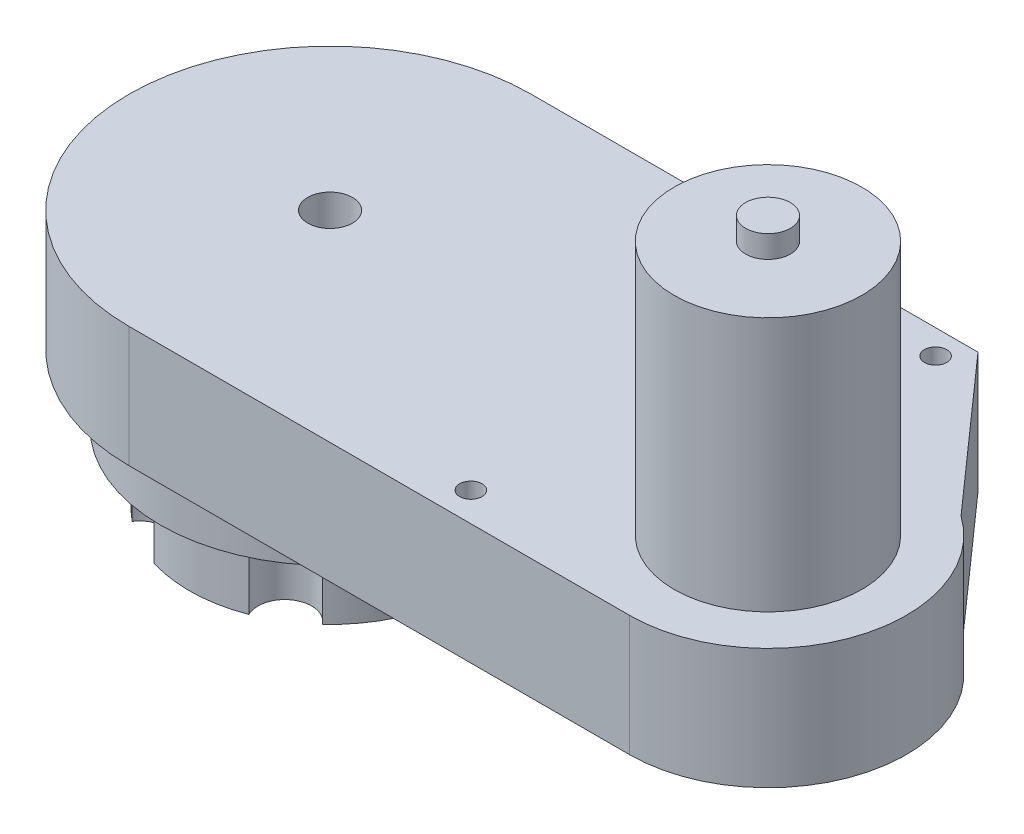
from build123d import *

# Parameters (mm, degrees)
SKETCH1_R                = 2.5
SKETCH1_R_2              = 5
BOSS_EXTRUDE1_DEPTH      = 27
SKETCH2_R                = 21
BOSS_EXTRUDE2_DEPTH      = 57
SKETCH4_R                = 38
SKETCH4_R_2              = 33
BOSS_EXTRUDE3_DEPTH      = 15
BOSS_EXTRUDE4_DEPTH      = 16
BOSS_EXTRUDE4_DEPTH_BACK = 15
SKETCH6_R                = 5
BOSS_EXTRUDE5_DEPTH      = 5
SKETCH7_R                = 33
BOSS_EXTRUDE6_DEPTH      = 15
SKETCH8_R                = 5
CUT_EXTRUDE1_DEPTH       = 87


with BuildPart() as part:
    # Sketch1 → Boss-Extrude1 (new body)
    with BuildSketch(Plane(origin=(0, 0, 0), x_dir=(1, 0, 0), z_dir=(0, 1, 0))):
        with BuildLine():
            Line((100, 45), (0, 45))
            ThreePointArc((0, 45), (-45, 0), (0, -45))
            Line((0, -45), (112, -45))
            ThreePointArc((112, -45), (141.550203848, -23.369389122), (129.862410225, 11.336422419))
            Line((129.862410225, 11.336422419), (100, 45))
        make_face()
        with Locations((70, -38.5)):
            Circle(SKETCH1_R, mode=Mode.SUBTRACT)
        with Locations((96, 39.5)):
            Circle(SKETCH1_R, mode=Mode.SUBTRACT)
        Circle(SKETCH1_R_2, mode=Mode.SUBTRACT)
    extrude(amount=BOSS_EXTRUDE1_DEPTH)

    # Sketch4 → Boss-Extrude3 (add)
    with BuildSketch(Plane.XZ):
        Circle(SKETCH4_R)
        Circle(SKETCH4_R_2, mode=Mode.SUBTRACT)
    extrude(amount=BOSS_EXTRUDE3_DEPTH)

    # Sketch5 → Boss-Extrude4 (add, two sides)
    with BuildSketch(Plane.XZ.offset(15)) as boss_extrude4_sk:
        with BuildLine():
            ThreePointArc((31.106124527, 4.96578462), (27.77659984, 14.856328662), (21.39833694, 23.116253507))
            ThreePointArc((21.39833694, 23.116253507), (13.460014521, 21.658208815), (11.252566633, 29.421586364))
            ThreePointArc((11.252566633, 29.421586364), (1.022341892, 31.483405423), (-9.320094308, 30.089630142))
            ThreePointArc((-9.320094308, 30.089630142), (-12.026551774, 22.485818918), (-19.853557895, 24.455801744))
            ThreePointArc((-19.853557895, 24.455801744), (-26.754257948, 16.627076761), (-30.718431248, 6.973376635))
            ThreePointArc((-30.718431248, 6.973376635), (-25.486566295, 0.827610103), (-31.106124527, -4.96578462))
            ThreePointArc((-31.106124527, -4.96578462), (-27.77659984, -14.856328662), (-21.39833694, -23.116253507))
            ThreePointArc((-21.39833694, -23.116253507), (-13.460014521, -21.658208815), (-11.252566633, -29.421586364))
            ThreePointArc((-11.252566633, -29.421586364), (-1.022341892, -31.483405423), (9.320094308, -30.089630142))
            ThreePointArc((9.320094308, -30.089630142), (12.026551774, -22.485818918), (19.853557895, -24.455801744))
            ThreePointArc((19.853557895, -24.455801744), (26.754257948, -16.627076761), (30.718431248, -6.973376635))
            ThreePointArc((30.718431248, -6.973376635), (25.486566295, -0.827610103), (31.106124527, 4.96578462))
        make_face()
        with BuildLine():
            ThreePointArc((20.020308468, -21.666500614), (25.055574904, -15.571389348), (28.291265465, -8.357888394))
            ThreePointArc((28.291265465, -8.357888394), (23.487619919, -0.762699507), (28.773894177, 6.504845418))
            ThreePointArc((28.773894177, 6.504845418), (26.0130062, 13.913069699), (21.383776403, 20.322010401))
            ThreePointArc((21.383776403, 20.322010401), (12.404327108, 19.959525771), (8.753585708, 28.171346032))
            ThreePointArc((8.753585708, 28.171346032), (0.957431296, 29.484459047), (-6.907489061, 28.679898795))
            ThreePointArc((-6.907489061, 28.679898795), (-11.083292811, 20.722225278), (-20.020308468, 21.666500614))
            ThreePointArc((-20.020308468, 21.666500614), (-25.055574904, 15.571389348), (-28.291265465, 8.357888394))
            ThreePointArc((-28.291265465, 8.357888394), (-23.487619919, 0.762699507), (-28.773894177, -6.504845418))
            ThreePointArc((-28.773894177, -6.504845418), (-26.0130062, -13.913069699), (-21.383776403, -20.322010401))
            ThreePointArc((-21.383776403, -20.322010401), (-12.404327108, -19.959525771), (-8.753585708, -28.171346032))
            ThreePointArc((-8.753585708, -28.171346032), (-0.957431296, -29.484459047), (6.907489061, -28.679898795))
            ThreePointArc((6.907489061, -28.679898795), (11.083292811, -20.722225278), (20.020308468, -21.666500614))
        make_face(mode=Mode.SUBTRACT)
    extrude(amount=BOSS_EXTRUDE4_DEPTH)
    extrude(boss_extrude4_sk.sketch, amount=-BOSS_EXTRUDE4_DEPTH_BACK)

    # Sketch7 → Boss-Extrude6 (add)
    with BuildSketch(Plane.XZ):
        Circle(SKETCH7_R)
    extrude(amount=BOSS_EXTRUDE6_DEPTH)

    # Sketch8 → Cut-Extrude1 (cut)
    with BuildSketch(Plane(origin=(0, 27, 0), x_dir=(1, 0, 0), z_dir=(0, 1, 0))):
        Circle(SKETCH8_R)
    extrude(amount=-CUT_EXTRUDE1_DEPTH, mode=Mode.SUBTRACT)


with BuildPart() as body_2:
    # Sketch2 → Boss-Extrude2 (new body)
    with BuildSketch(Plane(origin=(0, 27, 0), x_dir=(1, 0, 0), z_dir=(0, 1, 0))):
        with Locations((112, -14)):
            Circle(SKETCH2_R)
    extrude(amount=BOSS_EXTRUDE2_DEPTH)

    # Sketch6 → Boss-Extrude5 (add)
    with BuildSketch(Plane(origin=(0, 84, 0), x_dir=(1, 0, 0), z_dir=(0, 1, 0))):
        with Locations((112, -14)):
            Circle(SKETCH6_R)
    extrude(amount=BOSS_EXTRUDE5_DEPTH)


solid = Compound([part.part, body_2.part])
